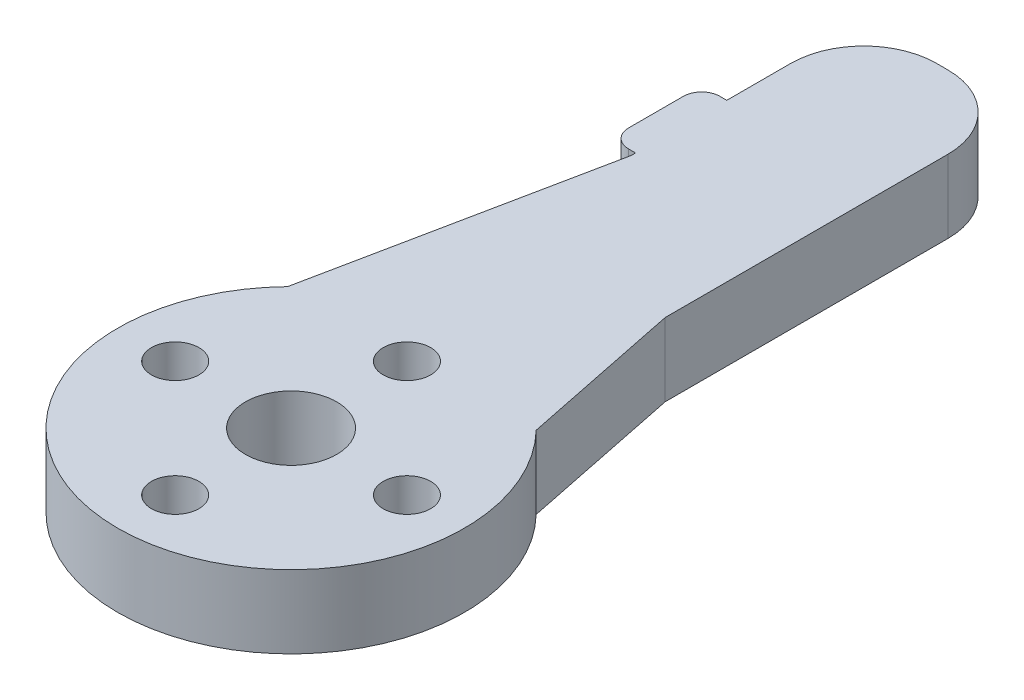
from build123d import *

# Parameters (mm, degrees)
SKETCH1_R           = 3
SKETCH1_R_2         = 2.5
BOSS_EXTRUDE1_DEPTH = 4
SKETCH2_R           = 1.3
CUT_EXTRUDE1_DEPTH  = 4
BOSS_EXTRUDE2_DEPTH = 4
SKETCH4_R           = 3
BOSS_EXTRUDE3_DEPTH = 4
SKETCH6_W           = 1.3795464
SKETCH6_H           = 7.5
CUT_EXTRUDE2_DEPTH  = 9
FILLET3_R           = 4
FILLET4_R           = 1


with BuildPart() as part:
    # Sketch1 → Boss-Extrude1 (new body)
    with BuildSketch(Plane(origin=(0, 0, 0), x_dir=(1, 0, 0), z_dir=(0, 1, 0))):
        with BuildLine():
            Line((-4.531642246, 17.7995776), (-7.838367177, 1.6))
            ThreePointArc((-7.838367177, 1.6), (0, -8), (7.838367177, 1.6))
            Line((7.838367177, 1.6), (4.531642246, 17.7995776))
            ThreePointArc((4.531642246, 17.7995776), (0, 21.499648), (-4.531642246, 17.7995776))
        make_face()
        with Locations(Location((0, 16.87456, 0), (0, 0, 270))):
            Circle(SKETCH1_R, mode=Mode.SUBTRACT)
        with Locations(Location((0, 0, 0), (0, 0, 270))):
            Circle(SKETCH1_R_2, mode=Mode.SUBTRACT)
    extrude(amount=BOSS_EXTRUDE1_DEPTH)

    # Sketch2 → Cut-Extrude1 (cut)
    with BuildSketch(Plane(origin=(0, 4, 0), x_dir=(1, 0, 0), z_dir=(0, 1, 0))):
        with Locations(Location((0, 6.35, 0), (0, 0, 270))):
            Circle(SKETCH2_R)
        with Locations(Location((6.35, 0, 0), (0, 0, 270))):
            Circle(SKETCH2_R)
        with Locations(Location((0, -6.35, 0), (0, 0, 270))):
            Circle(SKETCH2_R)
        with Locations(Location((-6.35, 0, 0), (0, 0, 270))):
            Circle(SKETCH2_R)
    extrude(amount=-CUT_EXTRUDE1_DEPTH, mode=Mode.SUBTRACT)

    # Sketch3 → Boss-Extrude2 (add)
    with BuildSketch(Plane(origin=(0, 4, 0), x_dir=(1, 0, 0), z_dir=(0, 1, 0))):
        with BuildLine():
            Line((-7.838367177, 1.6), (-6.8136721, 6.619960159))
            ThreePointArc((-6.8136721, 6.619960159), (0, -9.5), (6.8136721, 6.619960159))
            Line((6.8136721, 6.619960159), (7.838367177, 1.6))
            ThreePointArc((7.838367177, 1.6), (0, -8), (-7.838367177, 1.6))
        make_face()
    extrude(amount=-BOSS_EXTRUDE2_DEPTH)

    # Sketch4 → Boss-Extrude3 (add)
    with BuildSketch(Plane(origin=(0, 4, 0), x_dir=(1, 0, 0), z_dir=(0, 1, 0))):
        with BuildLine():
            Line((5, 35), (0, 35))
            Line((0, 35), (-5, 35))
            Line((-5, 35), (-5, 15.505102572))
            Line((-5, 15.505102572), (-4.531642246, 17.7995776))
            ThreePointArc((-4.531642246, 17.7995776), (0, 21.499648), (4.531642246, 17.7995776))
            Line((4.531642246, 17.7995776), (5, 15.505102572))
            Line((5, 15.505102572), (5, 35))
        make_face()
        with BuildLine():
            Line((5, 10), (5, 15.505102572))
            Line((5, 15.505102572), (4.531642246, 17.7995776))
            ThreePointArc((4.531642246, 17.7995776), (0, 21.499648), (-4.531642246, 17.7995776))
            Line((-4.531642246, 17.7995776), (-5, 15.505102572))
            Line((-5, 15.505102572), (-5, 10))
            Line((-5, 10), (0, 10))
            Line((0, 10), (5, 10))
        make_face()
        with Locations((0, 16.87456)):
            Circle(SKETCH4_R, mode=Mode.SUBTRACT)
        with Locations((0, 16.87456)):
            Circle(SKETCH4_R)
    extrude(amount=-BOSS_EXTRUDE3_DEPTH)

    # Sketch6 → Cut-Extrude2 (cut)
    with BuildSketch(Plane.XZ):
        with Locations((-4.3102268, -31.25)):
            Rectangle(SKETCH6_W, SKETCH6_H)
        Polygon((-3.6204536, -22.263472087), (-5, -15.505102572), (-5, -22.5), (-3.6204536, -22.5), align=None)
    extrude(amount=-CUT_EXTRUDE2_DEPTH, mode=Mode.SUBTRACT)

    # Fillet3
    fillet3_edges = [part.edges().sort_by_distance(p)[0] for p in [
        (5, 2, -35),
        (-3.6204536, 2, -35),
    ]]
    fillet(fillet3_edges, radius=FILLET3_R)

    # Fillet4
    fillet4_edges = [part.edges().sort_by_distance(p)[0] for p in [
        (-5, 2, -22.5),
        (-5, 2, -27.5),
    ]]
    fillet(fillet4_edges, radius=FILLET4_R)


solid = part.part
